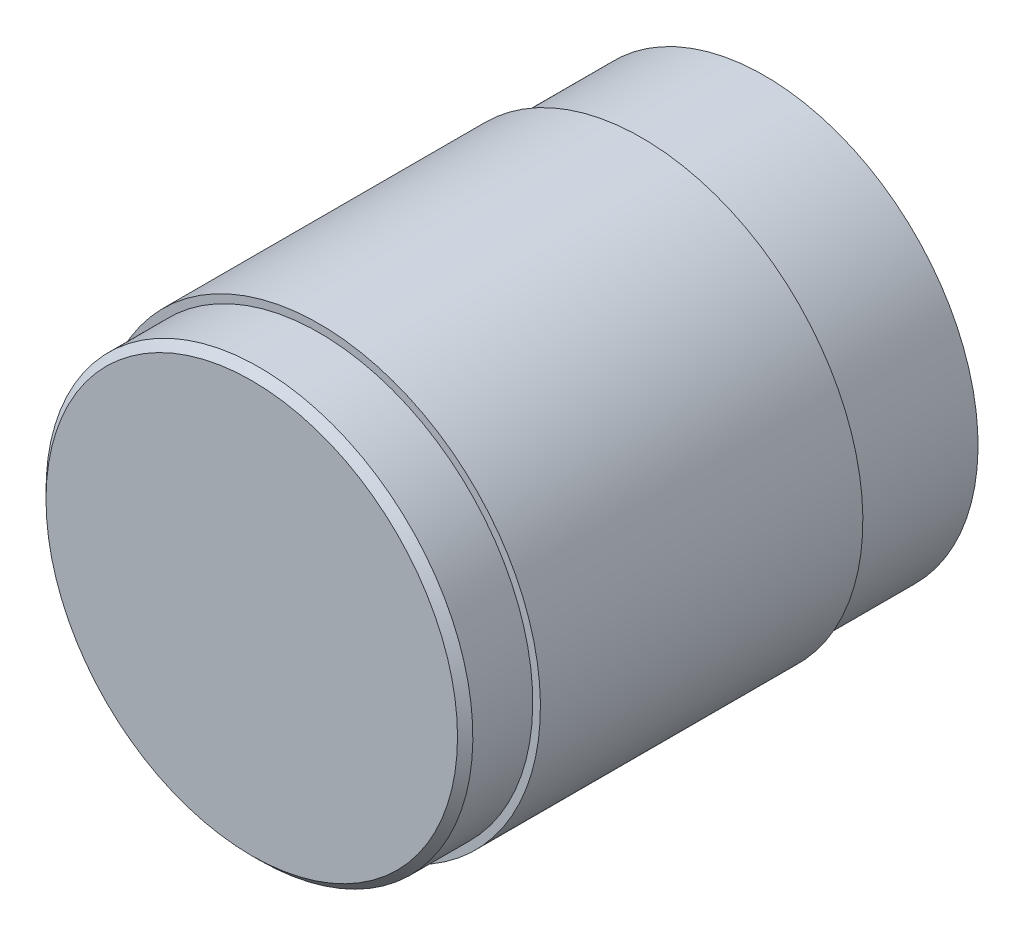
from build123d import *

# Parameters (mm, degrees)
BOSS_EXTRUDE1_START = 3.7
SKETCH2_R           = 6.95
BOSS_EXTRUDE1_DEPTH = 16.7
BOSS_EXTRUDE2_START = 1.5
SKETCH2_4_R         = 7.2
SKETCH2_4_R_2       = 6.95
BOSS_EXTRUDE2_DEPTH = 10.5
CHAMFER1_SIZE       = 0.25


with BuildPart() as part:
    # Sketch2 → Boss-Extrude1 (new body)
    with BuildSketch(Plane(origin=(0, -9.35e-07, 21.39999965), x_dir=(1, 0, 0), z_dir=(7.64274180725769e-15, -4.371138800000007e-08, 0.999999999999999)).offset(BOSS_EXTRUDE1_START)):
        with Locations((6.560058174, 8.001830475)):
            Circle(SKETCH2_R)
    extrude(amount=-BOSS_EXTRUDE1_DEPTH)

    # Sketch2_4 → Boss-Extrude2 (add)
    with BuildSketch(Plane(origin=(0, -9.35e-07, 21.39999965), x_dir=(1, 0, 0), z_dir=(7.64274180725769e-15, -4.371138800000007e-08, 0.999999999999999)).offset(BOSS_EXTRUDE2_START)):
        with Locations((6.560058174, 8.001830475)):
            Circle(SKETCH2_4_R)
        with Locations((6.560058174, 8.001830475)):
            Circle(SKETCH2_4_R_2, mode=Mode.SUBTRACT)
    extrude(amount=-BOSS_EXTRUDE2_DEPTH)

    # Chamfer1
    chamfer1_edges = [part.edges().sort_by_distance(p)[0] for p in [
        (-0.389941826, 8.001829378, 25.1),
    ]]
    chamfer(chamfer1_edges, length=CHAMFER1_SIZE)


solid = part.part
